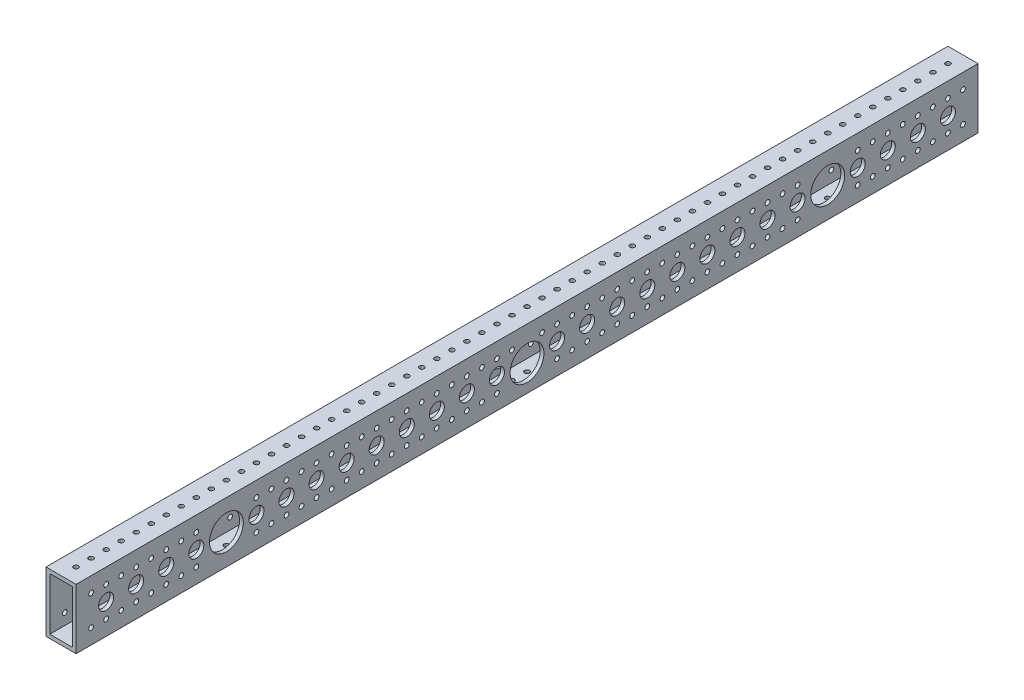
from build123d import *

# Parameters (mm, degrees)
SKETCH1_W                   = 25.4
SKETCH1_H                   = 50.8
BOSS_EXTRUDE1_DEPTH         = 762
SHELL1_T                    = -3.175
F_21_0_159_DIAMETER_HOLE1_D = 4.0386
LPATTERN1_COUNT             = 59
LPATTERN1_PITCH             = 12.7
F_21_0_159_DIAMETER_HOLE2_D = 4.0386
LPATTERN2_COUNT             = 59
LPATTERN2_PITCH             = 12.7
LPATTERN2_COUNT_DIR2        = 2
LPATTERN2_PITCH_DIR2        = 25.4
F_1_2_0_5_DIAMETER_HOLE1_D  = 12.7
LPATTERN3_COUNT             = 29
LPATTERN3_PITCH             = 25.4
F_97_1_125_DIAMETER_HOLE2_D = 28.575


with BuildPart() as part:
    # Sketch1 → Boss-Extrude1 (new body)
    with BuildSketch(Plane.XY):
        Rectangle(SKETCH1_W, SKETCH1_H)
    extrude(amount=BOSS_EXTRUDE1_DEPTH)

    # Shell1
    shell1_openings = [part.faces().sort_by_distance(p)[0] for p in [
        (0, 0, 762),
        (0, 0, 0),
    ]]
    offset(amount=SHELL1_T, openings=shell1_openings, kind=Kind.INTERSECTION)

    # #21 (0.159) Diameter Hole1 (through all)
    with Locations(Plane(origin=(0, 25.4, 0), x_dir=(1, 0, 0), z_dir=(0, 1, 0))):
        with Locations((0, -12.7)):
            f_21_0_159_diameter_hole1 = Hole(F_21_0_159_DIAMETER_HOLE1_D / 2)

    # LPattern1: #21 (0.159) Diameter Hole1 ×59
    with Locations(*[(0, 0, i * LPATTERN1_PITCH) for i in range(1, LPATTERN1_COUNT)]):
        add(f_21_0_159_diameter_hole1, mode=Mode.SUBTRACT)

    # #21 (0.159) Diameter Hole2 (through all)
    with Locations(Plane.ZY.offset(12.7)):
        with Locations((12.7, 12.7)):
            f_21_0_159_diameter_hole2 = Hole(F_21_0_159_DIAMETER_HOLE2_D / 2)

    # LPattern2: 21 _0.159_ Diameter Hole2 59 × 2, 16 skipped
    with Locations(*[(0, -j * LPATTERN2_PITCH_DIR2, i * LPATTERN2_PITCH) for i in range(LPATTERN2_COUNT) for j in range(LPATTERN2_COUNT_DIR2) if (i, j) not in ((0, 0), (8, 0), (8, 1), (9, 0), (9, 1), (10, 0), (10, 1), (28, 1), (29, 0), (29, 1), (30, 1), (48, 0), (48, 1), (49, 0), (49, 1), (50, 0), (50, 1))]):
        add(f_21_0_159_diameter_hole2, mode=Mode.SUBTRACT)

    # 1/2 (0.5) Diameter Hole1 (through all)
    with Locations(Plane.ZY.offset(12.7)):
        with Locations((25.4, 0)):
            f_1_2_0_5_diameter_hole1 = Hole(F_1_2_0_5_DIAMETER_HOLE1_D / 2)

    # LPattern3: 1/2 (0.5) Diameter Hole1 ×29, 3 skipped
    with Locations(*[(0, 0, i * LPATTERN3_PITCH) for i in range(1, LPATTERN3_COUNT) if i not in (4, 14, 24)]):
        add(f_1_2_0_5_diameter_hole1, mode=Mode.SUBTRACT)

    # #97 (1.125) Diameter Hole2 (through all)
    with Locations(Plane.ZY.offset(12.7)):
        with Locations((127, 0), (635, 0), (381, -3.175)):
            Hole(F_97_1_125_DIAMETER_HOLE2_D / 2)


solid = part.part
